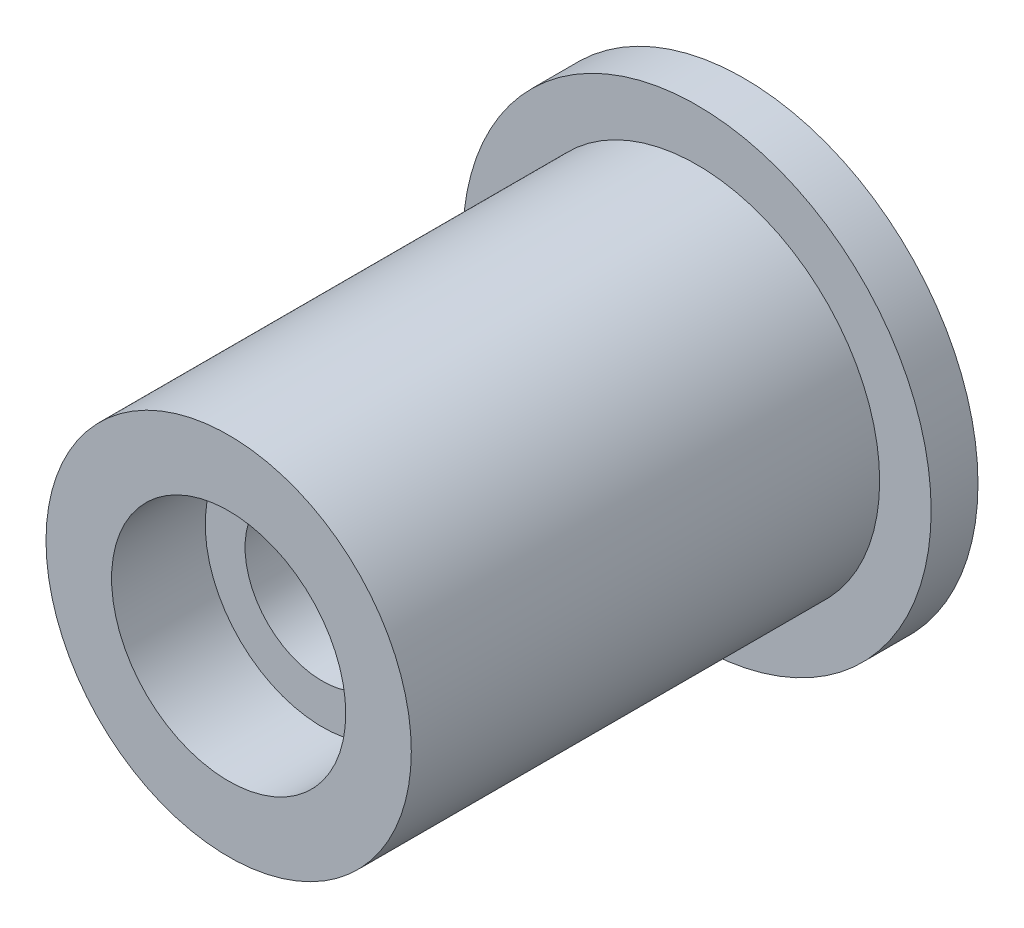
from build123d import *

# Parameters (mm, degrees)
SKETCH1_R           = 5
SKETCH1_R_2         = 1.65
BOSS_EXTRUDE1_DEPTH = 1
SKETCH1_3_R         = 3.9
SKETCH1_3_R_2       = 2.5
BOSS_EXTRUDE2_DEPTH = 10
SKETCH1_4_R         = 2.5
SKETCH1_4_R_2       = 1.65
BOSS_EXTRUDE3_DEPTH = 8


with BuildPart() as part:
    # Sketch1 → Boss-Extrude1 (new body)
    with BuildSketch(Plane.XY):
        Circle(SKETCH1_R)
        Circle(SKETCH1_R_2, mode=Mode.SUBTRACT)
    extrude(amount=-BOSS_EXTRUDE1_DEPTH)

    # Sketch1_3 → Boss-Extrude2 (add)
    with BuildSketch(Plane.XY):
        Circle(SKETCH1_3_R)
        Circle(SKETCH1_3_R_2, mode=Mode.SUBTRACT)
    extrude(amount=BOSS_EXTRUDE2_DEPTH)

    # Sketch1_4 → Boss-Extrude3 (add)
    with BuildSketch(Plane.XY):
        Circle(SKETCH1_4_R)
        Circle(SKETCH1_4_R_2, mode=Mode.SUBTRACT)
    extrude(amount=BOSS_EXTRUDE3_DEPTH)


solid = part.part
